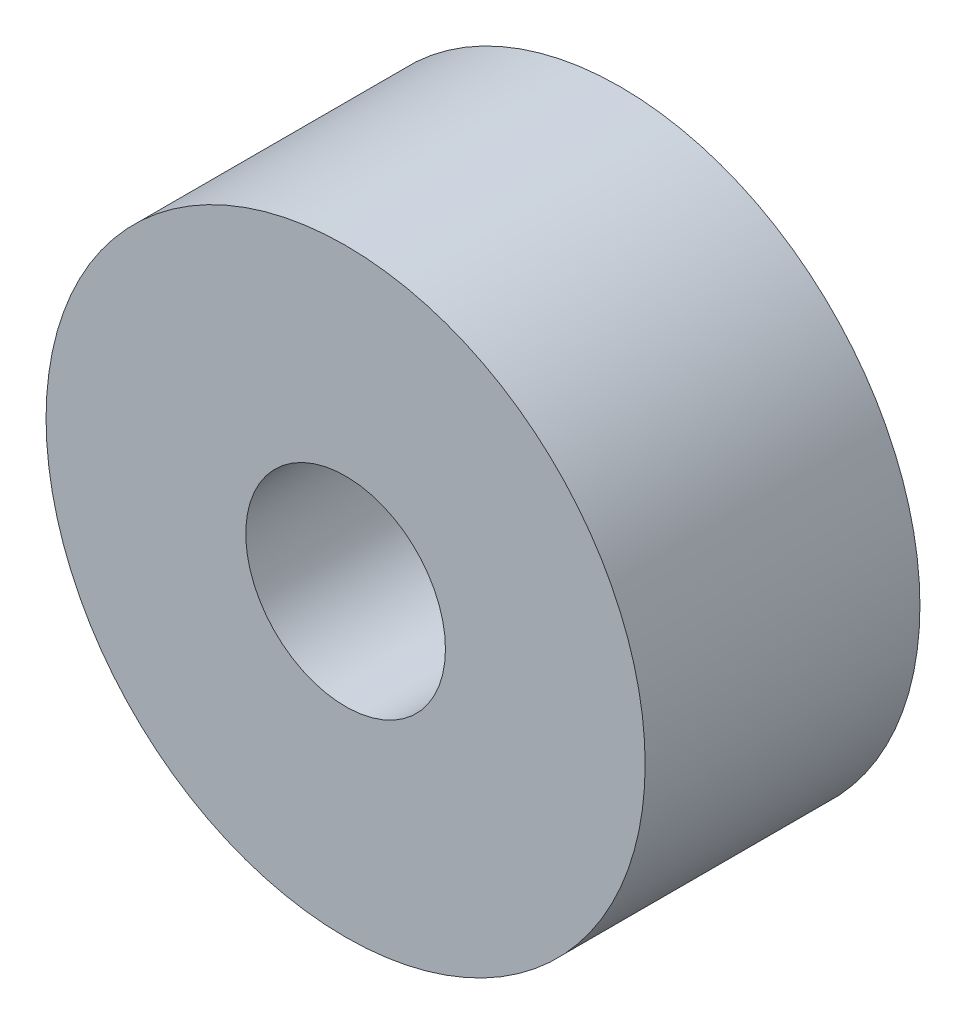
from build123d import *

# Parameters (mm, degrees)
SKETCH1_R           = 7.5
SKETCH1_R_2         = 2.5
BOSS_EXTRUDE1_DEPTH = 6.88


with BuildPart() as part:
    # Sketch1 → Boss-Extrude1 (new body)
    with BuildSketch(Plane.XY):
        Circle(SKETCH1_R)
        Circle(SKETCH1_R_2, mode=Mode.SUBTRACT)
    extrude(amount=BOSS_EXTRUDE1_DEPTH)


solid = part.part
